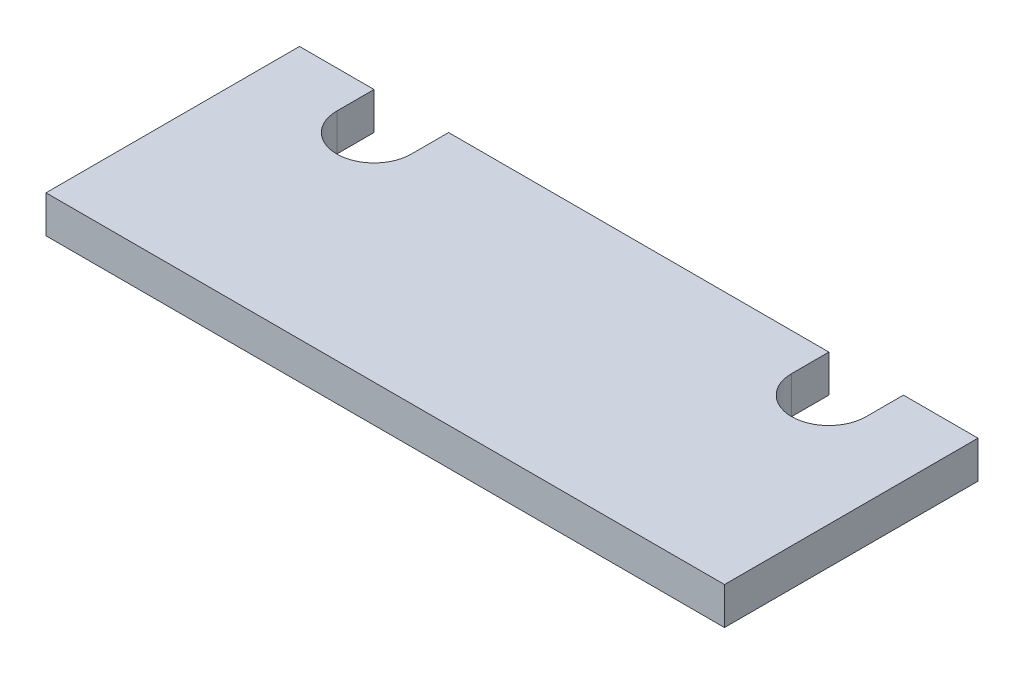
from build123d import *

# Parameters (mm, degrees)
SKETCH1_W           = 115.57
SKETCH1_H           = 43.18
BOSS_EXTRUDE1_DEPTH = 6.35
CUT_EXTRUDE1_DEPTH  = 7.35


with BuildPart() as part:
    # Sketch1 → Boss-Extrude1 (new body)
    with BuildSketch(Plane(origin=(0, 0, 0), x_dir=(1, 0, 0), z_dir=(0, 1, 0))):
        with Locations((57.785, 21.59)):
            Rectangle(SKETCH1_W, SKETCH1_H)
    extrude(amount=BOSS_EXTRUDE1_DEPTH)

    # Sketch2 → Cut-Extrude1 (cut, through all)
    with BuildSketch(Plane(origin=(0, 6.35, 0), x_dir=(1, 0, 0), z_dir=(0, 1, 0))):
        with BuildLine():
            Line((25.4, 52.705), (25.4, 36.83))
            ThreePointArc((25.4, 36.83), (19.05, 30.48), (12.7, 36.83))
            Line((12.7, 36.83), (12.7, 52.705))
            Line((12.7, 52.705), (25.4, 52.705))
        make_face()
        with BuildLine():
            Line((102.87, 52.705), (90.17, 52.705))
            Line((90.17, 52.705), (90.17, 36.83))
            ThreePointArc((90.17, 36.83), (96.52, 30.48), (102.87, 36.83))
            Line((102.87, 36.83), (102.87, 52.705))
        make_face()
    extrude(amount=-CUT_EXTRUDE1_DEPTH, mode=Mode.SUBTRACT)


solid = part.part
